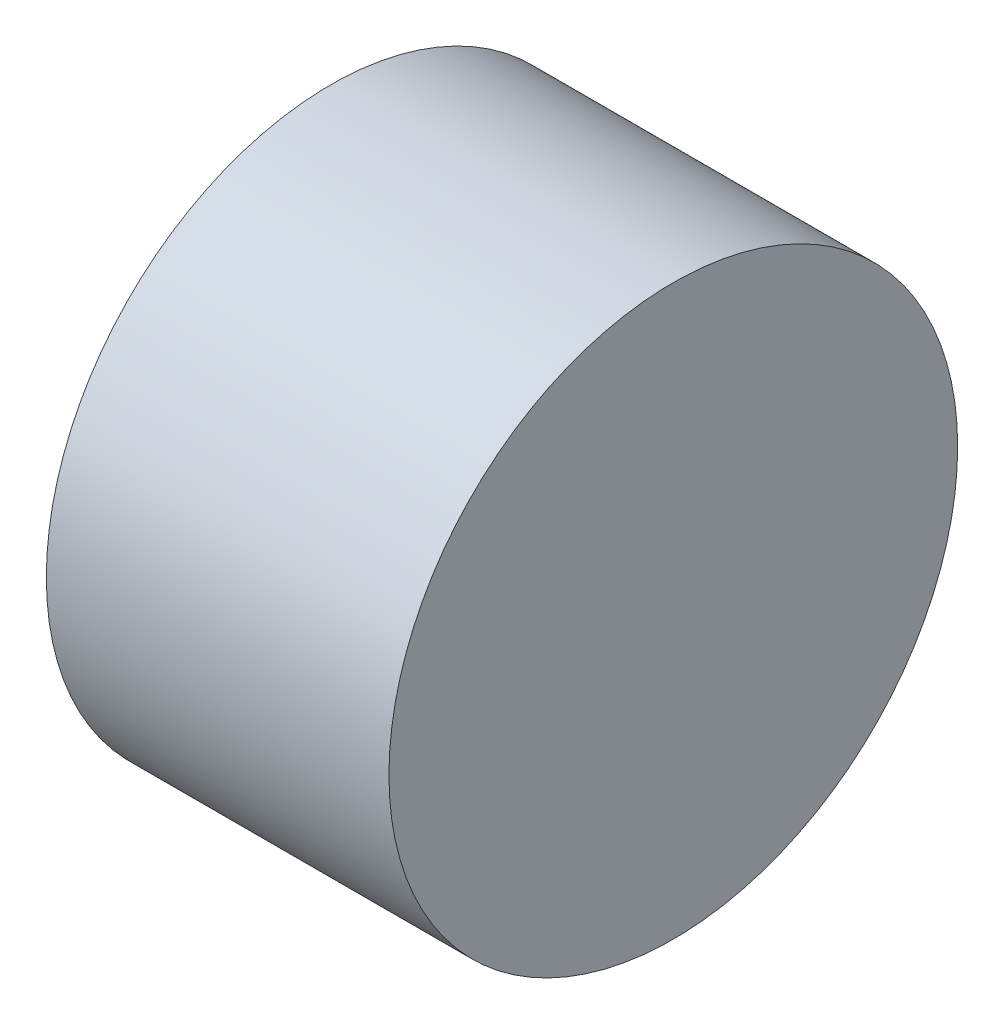
from build123d import *

# Parameters (mm, degrees)
SKETCH1_W          = 25.4
SKETCH1_H          = 21.082
SKETCH2_R          = 1.984375
CUT_EXTRUDE1_DEPTH = 6.35


with BuildPart() as part:
    # Sketch1 → Revolve1 (revolve)
    with BuildSketch(Plane.XY):
        with Locations((12.7, 10.541)):
            Rectangle(SKETCH1_W, SKETCH1_H)
    revolve(axis=Axis((-29.670962963, 0, 0), (1, 0, 0)))

    # Sketch2 → Cut-Extrude1 (cut)
    with BuildSketch(Plane.ZY):
        with Locations((0, 11.1125)):
            Circle(SKETCH2_R)
        with Locations((11.1125, 0)):
            Circle(SKETCH2_R)
        with Locations((0, -11.1125)):
            Circle(SKETCH2_R)
        with Locations((-11.1125, 0)):
            Circle(SKETCH2_R)
    extrude(amount=-CUT_EXTRUDE1_DEPTH, mode=Mode.SUBTRACT)


solid = part.part
